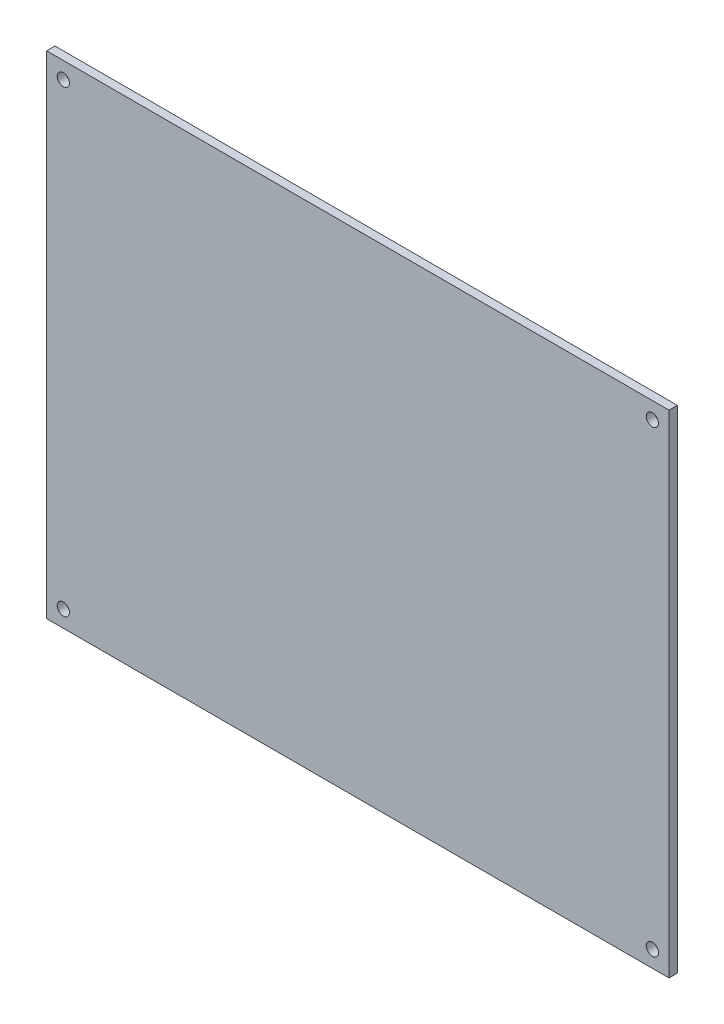
from build123d import *

# Parameters (mm, degrees)
SKETCH1_W           = 112
SKETCH1_H           = 88.5
BOSS_EXTRUDE1_DEPTH = 1.5
SKETCH2_R           = 1.1
CUT_EXTRUDE1_DEPTH  = 2.5


with BuildPart() as part:
    # Sketch1 → Boss-Extrude1 (new body)
    with BuildSketch(Plane.XY):
        Rectangle(SKETCH1_W, SKETCH1_H)
    extrude(amount=BOSS_EXTRUDE1_DEPTH)

    # Sketch2 → Cut-Extrude1 (cut, through all)
    with BuildSketch(Plane.XY.offset(1.5)):
        with Locations((-53, 41.25)):
            Circle(SKETCH2_R)
        with Locations((53, 41.25)):
            Circle(SKETCH2_R)
        with Locations((53, -41.25)):
            Circle(SKETCH2_R)
        with Locations((-53, -41.25)):
            Circle(SKETCH2_R)
    extrude(amount=-CUT_EXTRUDE1_DEPTH, mode=Mode.SUBTRACT)


solid = part.part
